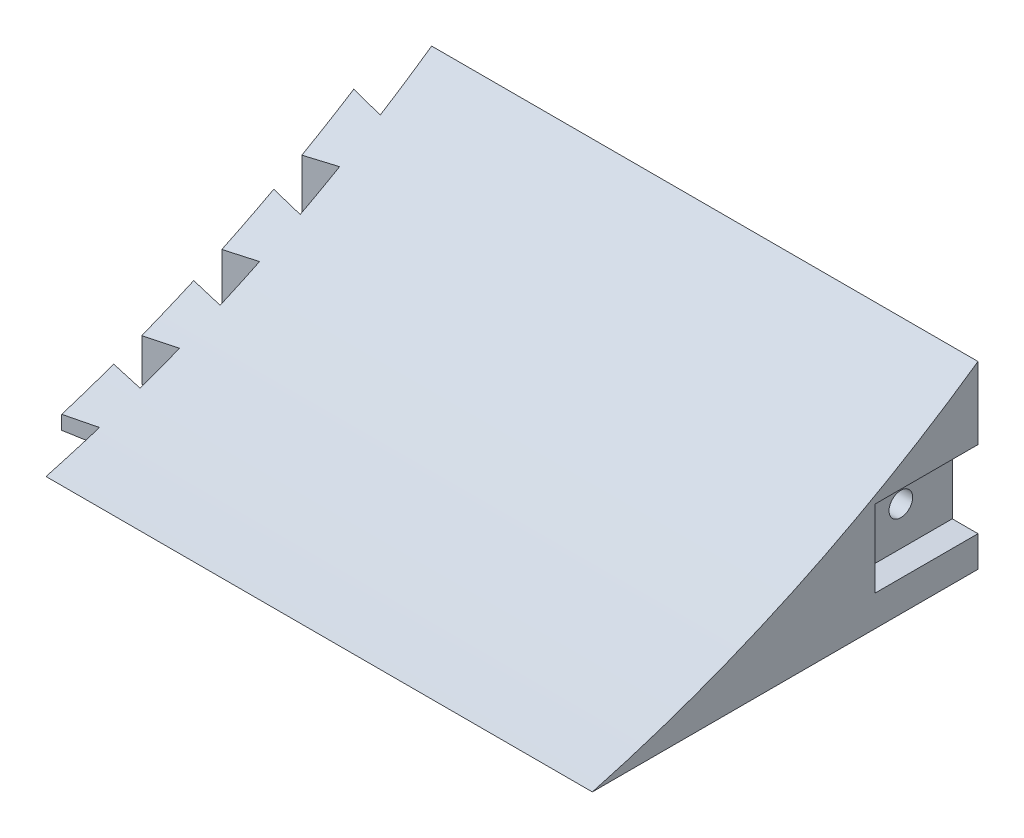
from build123d import *

# Parameters (mm, degrees)
BOSS_EXTRUDE1_DEPTH = 134.9375
SKETCH4_W           = 25.4
SKETCH4_H           = 19.05
CUT_EXTRUDE1_DEPTH  = 6.35
SKETCH6_R           = 2.921
CUT_EXTRUDE3_DEPTH  = 25.4
BOSS_EXTRUDE2_DEPTH = 38.1
CUT_EXTRUDE4_DEPTH  = 143.860280702


with BuildPart() as part:
    # Sketch3 → Boss-Extrude1 (new body)
    with BuildSketch(Plane(origin=(0, 0, 0), x_dir=(0, 0, -1), z_dir=(1, 0, 0))):
        with BuildLine():
            Line((0, 0), (95.25, 0))
            Line((95.25, 0), (95.25, 44.45))
            ThreePointArc((95.25, 44.45), (49.555547135, 18.088113282), (0, 0))
        make_face()
    extrude(amount=BOSS_EXTRUDE1_DEPTH)

    # Sketch4 → Cut-Extrude1 (cut)
    with BuildSketch(Plane(origin=(134.9375, 0, 0), x_dir=(0, 0, -1), z_dir=(1, 0, 0))):
        with Locations((82.55, 17.145)):
            Rectangle(SKETCH4_W, SKETCH4_H)
    extrude(amount=-CUT_EXTRUDE1_DEPTH, mode=Mode.SUBTRACT)

    # Sketch6 → Cut-Extrude3 (cut)
    with BuildSketch(Plane(origin=(128.5875, 0, 0), x_dir=(0, 0, -1), z_dir=(1, 0, 0))):
        with Locations((82.55, 17.145)):
            Circle(SKETCH6_R)
    extrude(amount=-CUT_EXTRUDE3_DEPTH, mode=Mode.SUBTRACT)

    # Sketch7 → Boss-Extrude2 (add)
    with BuildSketch(Plane.XZ):
        Polygon((0, -82.55), (-7.922780702, -83.947), (-7.922780702, -71.12), (0, -72.517), align=None)
        Polygon((0, -62.780333333), (-7.922780702, -64.177333333), (-7.922780702, -51.350333333), (0, -52.747333333), align=None)
        Polygon((0, -43.010666667), (-7.922780702, -44.407666667), (-7.922780702, -31.580666667), (0, -32.977666667), align=None)
        Polygon((0, -23.241), (-7.922780702, -24.638), (-7.922780702, -11.811), (0, -13.208), align=None)
    extrude(amount=-BOSS_EXTRUDE2_DEPTH)

    # Sketch8 → Cut-Extrude4 (cut, through all)
    with BuildSketch(Plane(origin=(134.9375, 0, 0), x_dir=(0, 0, -1), z_dir=(1, 0, 0))):
        with BuildLine():
            Line((95.25, 44.45), (0, 44.45))
            Line((0, 44.45), (0, 0))
            ThreePointArc((0, 0), (49.555547135, 18.088113282), (95.25, 44.45))
        make_face()
    extrude(amount=-CUT_EXTRUDE4_DEPTH, mode=Mode.SUBTRACT)


solid = part.part
